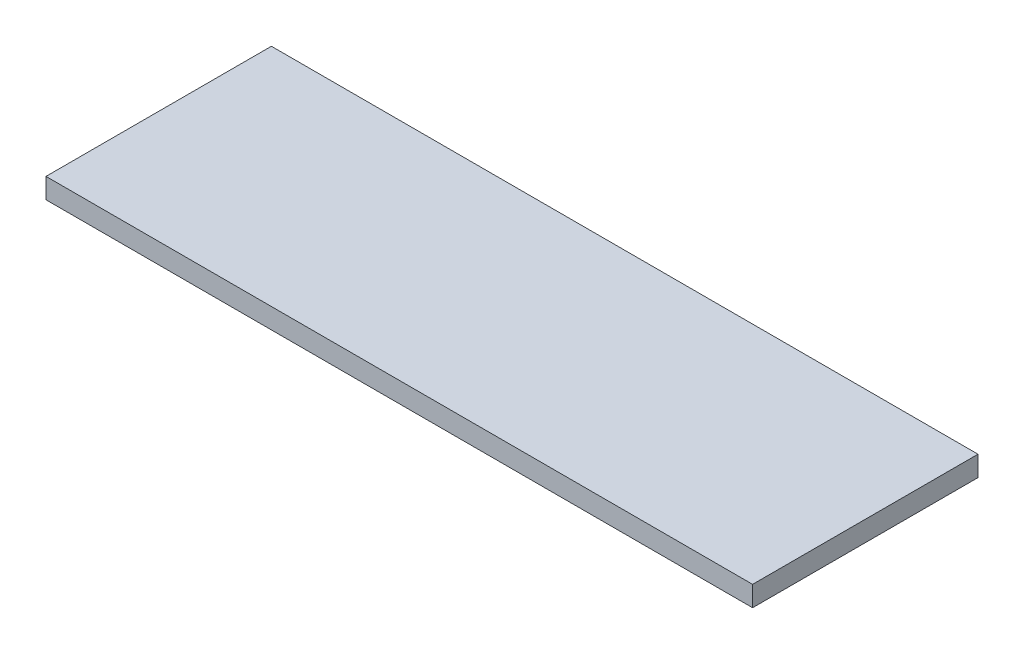
from build123d import *

# Parameters (mm, degrees)
SKETCH_1_W      = 627
SKETCH_1_H      = 200
EXTRUDE_1_DEPTH = 18


with BuildPart() as part:
    # Эскиз1 → Бобышка-Вытянуть1 (new body)
    with BuildSketch(Plane(origin=(0, 0, 0), x_dir=(1, 0, 0), z_dir=(0, 1, 0))):
        Rectangle(SKETCH_1_W, SKETCH_1_H)
    extrude(amount=EXTRUDE_1_DEPTH)


solid = part.part
